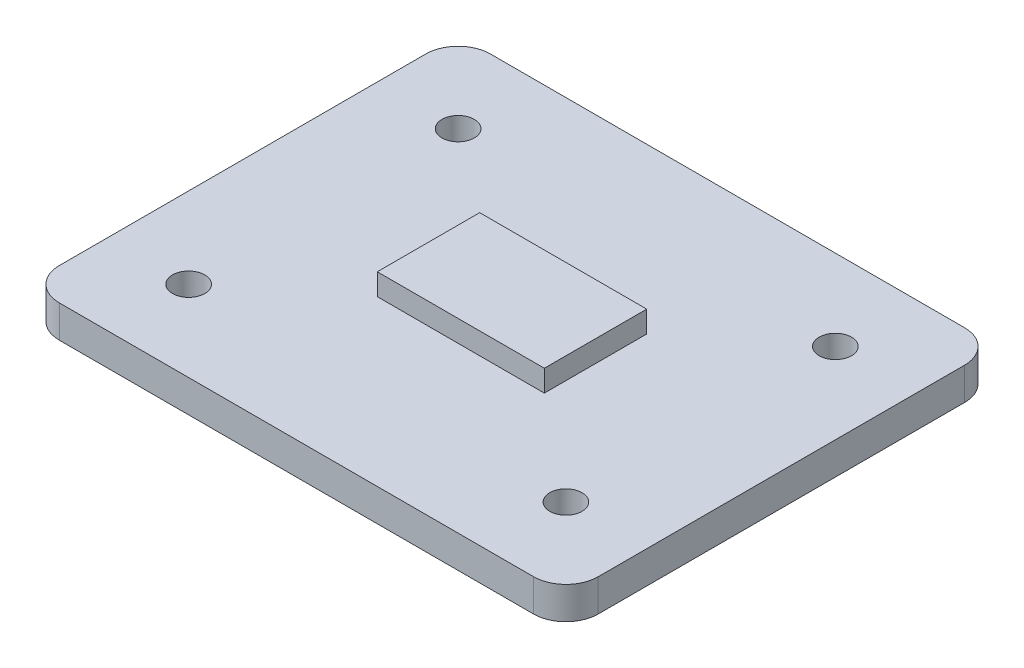
from build123d import *

# Parameters (mm, degrees)
SKETCH1_W     = 50
SKETCH1_H     = 40
BODY_DEPTH    = 3
FILLET_BODY_R = 3
SKETCH2_R     = 1.5
BOLTS_DEPTH   = 9
SKETCH3_W     = 15.5
SKETCH3_H     = 9.5
CHANNEL_DEPTH = 2


with BuildPart() as part:
    # Sketch1 → Body (new body)
    with BuildSketch(Plane(origin=(0, 0, 0), x_dir=(1, 0, 0), z_dir=(0, 1, 0))):
        Rectangle(SKETCH1_W, SKETCH1_H)
    extrude(amount=BODY_DEPTH)

    # Fillet_Body
    fillet_body_edges = [part.edges().sort_by_distance(p)[0] for p in [
        (-25, 1.5, -20),
        (25, 1.5, -20),
        (25, 1.5, 20),
        (-25, 1.5, 20),
    ]]
    fillet(fillet_body_edges, radius=FILLET_BODY_R)

    # Sketch2 → Bolts (cut)
    with BuildSketch(Plane(origin=(0, 3, 0), x_dir=(1, 0, 0), z_dir=(0, 1, 0))):
        with Locations((-17.5, 12.5)):
            Circle(SKETCH2_R)
        with Locations((17.5, 12.5)):
            Circle(SKETCH2_R)
        with Locations((17.5, -12.5)):
            Circle(SKETCH2_R)
        with Locations((-17.5, -12.5)):
            Circle(SKETCH2_R)
    extrude(amount=-BOLTS_DEPTH, mode=Mode.SUBTRACT)

    # Sketch3 → Channel (add)
    with BuildSketch(Plane(origin=(0, 3, 0), x_dir=(1, 0, 0), z_dir=(0, 1, 0))):
        Rectangle(SKETCH3_W, SKETCH3_H)
    extrude(amount=CHANNEL_DEPTH)


solid = part.part
